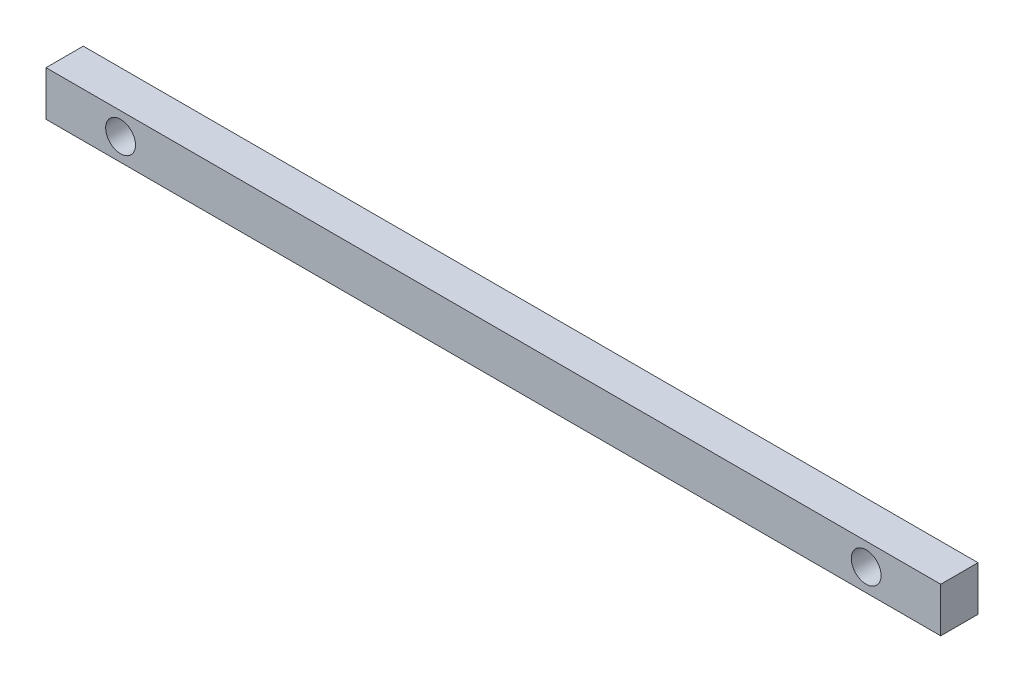
from build123d import *

# Parameters (mm, degrees)
SKETCH1_W           = 120
SKETCH1_H           = 6
SKETCH1_R           = 2
BOSS_EXTRUDE1_DEPTH = 5


with BuildPart() as part:
    # Sketch1 → Boss-Extrude1 (new body)
    with BuildSketch(Plane.XY):
        Rectangle(SKETCH1_W, SKETCH1_H)
        with Locations((-50, 0)):
            Circle(SKETCH1_R, mode=Mode.SUBTRACT)
        with Locations((50, 0)):
            Circle(SKETCH1_R, mode=Mode.SUBTRACT)
    extrude(amount=BOSS_EXTRUDE1_DEPTH)


solid = part.part
